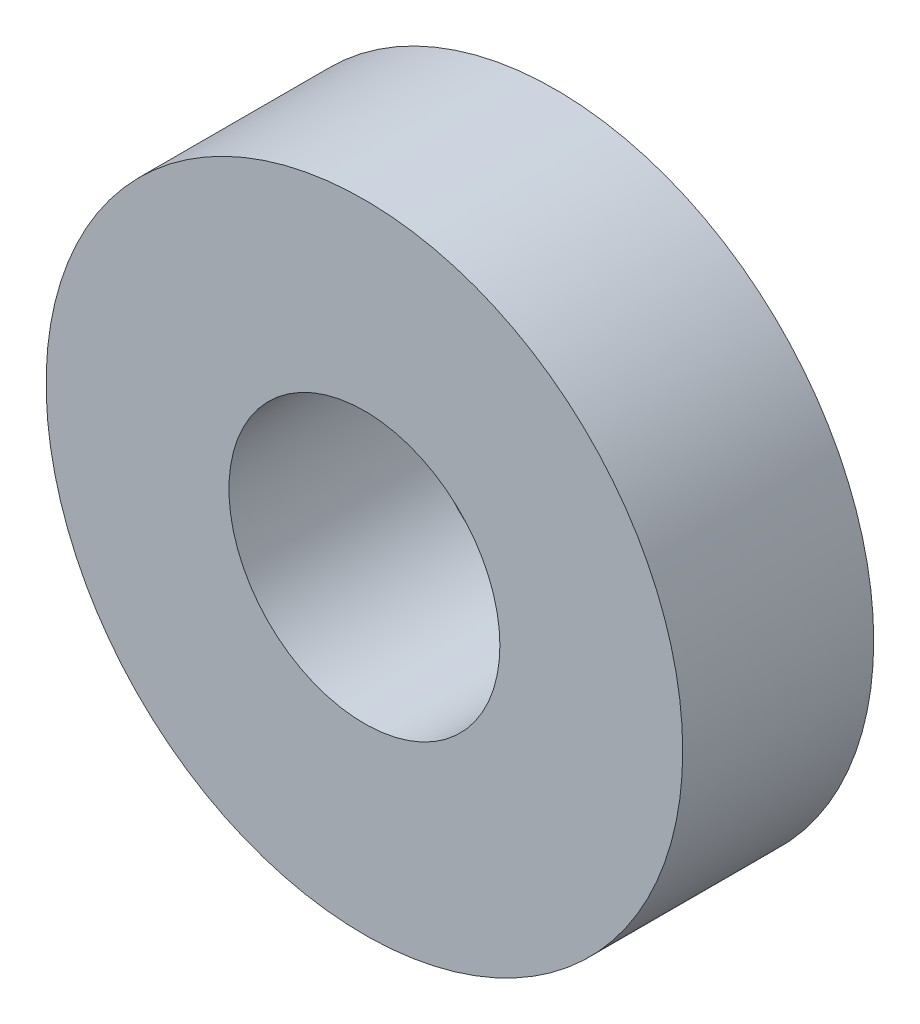
from build123d import *

# Parameters (mm, degrees)
SKETCH1_R           = 7.9375
BOSS_EXTRUDE1_DEPTH = 2.38125
CUT_EXTRUDE1_REACH  = 6.763
SKETCH2_R           = 3.3782


with BuildPart() as part:
    # Sketch1 → Boss-Extrude1 (new body, symmetric)
    with BuildSketch(Plane.XY):
        Circle(SKETCH1_R)
    extrude(amount=BOSS_EXTRUDE1_DEPTH, both=True)

    # Sketch2 → Cut-Extrude1 (cut, up to next)
    with BuildSketch(Plane.XY.offset(2.38125), mode=Mode.PRIVATE) as cut_extrude1_sk1:
        Circle(SKETCH2_R)
    cut_extrude1_tool1 = extrude(cut_extrude1_sk1.sketch, amount=-CUT_EXTRUDE1_REACH, mode=Mode.PRIVATE) & part.part
    add(cut_extrude1_tool1.solids().sort_by_distance((0, 0, 2.38125))[0], mode=Mode.SUBTRACT)


solid = part.part
